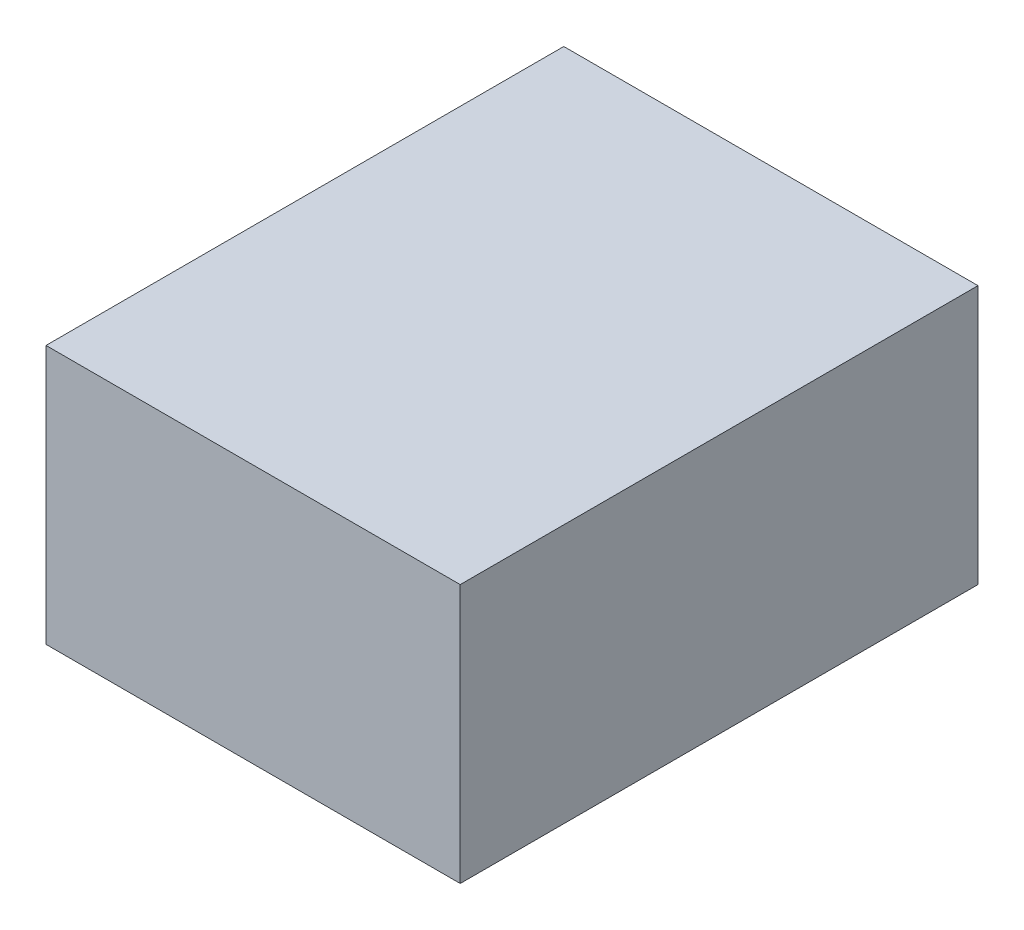
from build123d import *

# Parameters (mm, degrees)
BOSS_EXTRUDE1_START = 3
SKETCH1_W           = 40
SKETCH1_H           = 50
BOSS_EXTRUDE1_DEPTH = 25


with BuildPart() as part:
    # Sketch1 → Boss-Extrude1 (new body)
    with BuildSketch(Plane(origin=(0, 0, 0), x_dir=(1, 0, 0), z_dir=(0, 1, 0)).offset(BOSS_EXTRUDE1_START)):
        Rectangle(SKETCH1_W, SKETCH1_H)
    extrude(amount=BOSS_EXTRUDE1_DEPTH)


solid = part.part
